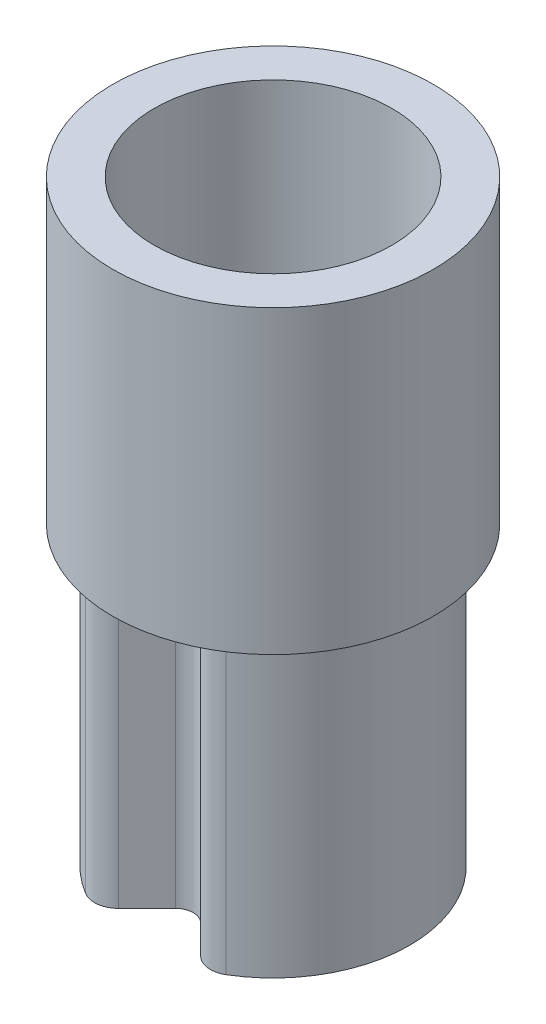
from build123d import *

# Parameters (mm, degrees)
BOSS_EXTRUDE1_DEPTH = 2.5
FILLET1_R           = 0.05
FILLET2_R           = 0.2
SKETCH2_R           = 1.35
SKETCH2_R_2         = 1
BOSS_EXTRUDE2_DEPTH = 2.53


with BuildPart() as part:
    # Sketch1 → Boss-Extrude1 (new body)
    with BuildSketch(Plane(origin=(0, 0, 0), x_dir=(1, 0, 0), z_dir=(0, 1, 0))):
        with BuildLine():
            Line((-0.448807004, -1.058807004), (-0.106066017, -0.716066017))
            ThreePointArc((-0.106066017, -0.716066017), (0, -0.672132034), (0.106066017, -0.716066017))
            Line((0.106066017, -0.716066017), (0.448807004, -1.058807004))
            ThreePointArc((0.448807004, -1.058807004), (0, 1.15), (-0.448807004, -1.058807004))
        make_face()
        with BuildLine():
            Line((-0.479612457, -0.877480422), (-0.212132034, -0.61))
            ThreePointArc((-0.212132034, -0.61), (0, -0.522132034), (0.212132034, -0.61))
            Line((0.212132034, -0.61), (0.479612457, -0.877480422))
            ThreePointArc((0.479612457, -0.877480422), (0, 1), (-0.479612457, -0.877480422))
        make_face(mode=Mode.SUBTRACT)
    extrude(amount=BOSS_EXTRUDE1_DEPTH)

    # Fillet1
    fillet1_edges = [part.edges().sort_by_distance(p)[0] for p in [
        (0.479612457, 1.25, 0.877480422),
        (-0.479612457, 1.25, 0.877480422),
    ]]
    fillet(fillet1_edges, radius=FILLET1_R)

    # Fillet2
    fillet2_edges = [part.edges().sort_by_distance(p)[0] for p in [
        (-0.448807004, 1.25, 1.058807004),
        (0.448807004, 1.25, 1.058807004),
    ]]
    fillet(fillet2_edges, radius=FILLET2_R)

    # Sketch2 → Boss-Extrude2 (add)
    with BuildSketch(Plane(origin=(0, 2.5, 0), x_dir=(1, 0, 0), z_dir=(0, 1, 0))):
        Circle(SKETCH2_R)
        Circle(SKETCH2_R_2, mode=Mode.SUBTRACT)
    extrude(amount=BOSS_EXTRUDE2_DEPTH)


solid = part.part
